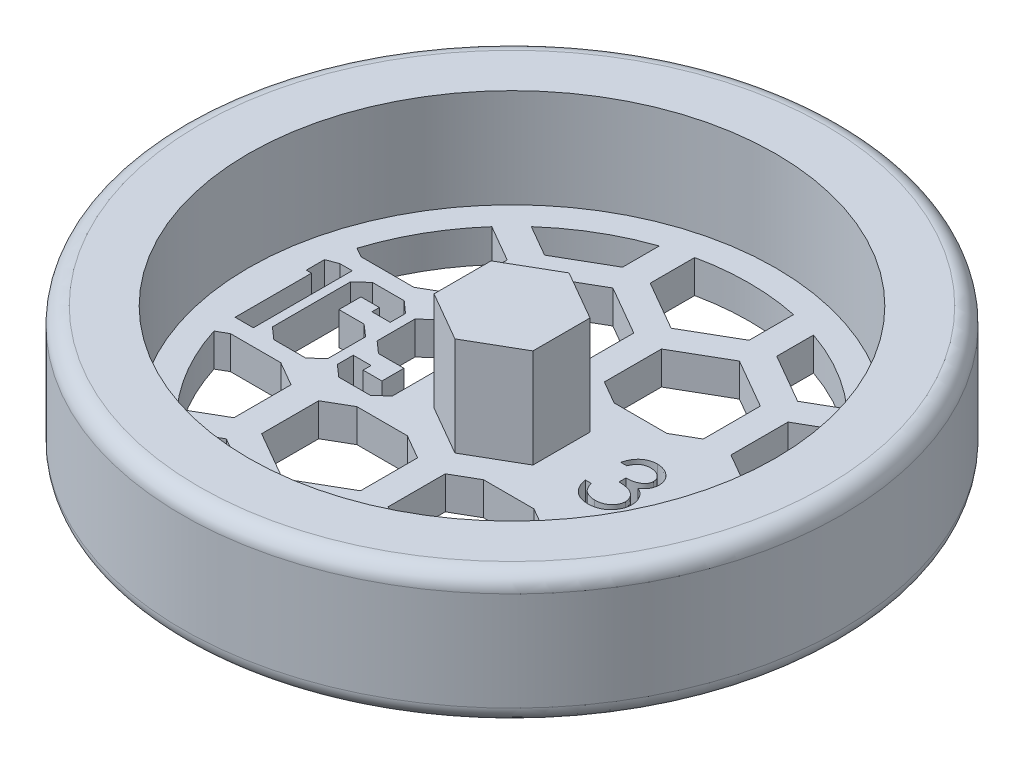
from build123d import *

# Parameters (mm, degrees)
BOSS_EXTRUDE1_DEPTH     = 9.525
CUT_EXTRUDE1_DEPTH      = 10.5250001
CUT_EXTRUDE1_DEPTH_BACK = 4.175
CUT_EXTRUDE3_DEPTH      = 10.5250001
CUT_EXTRUDE3_DEPTH_BACK = 4.1750001


with BuildPart() as part:
    # Sketch1 → Revolve1 (revolve)
    with BuildSketch(Plane.XY):
        with BuildLine():
            Line((0, 0), (30.1625, 0))
            ThreePointArc((30.1625, 0), (31.285032015, 0.464967985), (31.75, 1.5875))
            Line((31.75, 1.5875), (31.75, 11.1125))
            ThreePointArc((31.75, 11.1125), (31.285032015, 12.235032015), (30.1625, 12.7))
            Line((30.1625, 12.7), (25.4, 12.7))
            Line((25.4, 12.7), (25.4, 3.175))
            Line((25.4, 3.175), (0, 3.175))
            Line((0, 3.175), (0, 0))
        make_face()
    revolve(axis=Axis((0, 3.175, 0), (0, -1, 0)))

    # Sketch2 → Boss-Extrude1 (add)
    with BuildSketch(Plane(origin=(0, 3.175, 0), x_dir=(1, 0, 0), z_dir=(0, 1, 0))):
        Polygon((0, -5.499261314), (4.7625, -2.749630657), (4.7625, 2.749630657), (0, 5.499261314), (-4.7625, 2.749630657), (-4.7625, -2.749630657), align=None)
    extrude(amount=BOSS_EXTRUDE1_DEPTH)

    # Sketch3 → Cut-Extrude1 (cut, two sides)
    with BuildSketch(Plane(origin=(0, 3.175, 0), x_dir=(1, 0, 0), z_dir=(0, 1, 0))) as cut_extrude1_sk:
        Polygon((-20.156339589, -4.7625), (-21.915105149, -4.7625), (-21.915105149, 2.597727273), (-22.418122878, 2.597727273), (-22.418122878, 4.356492833), (-21.333041777, 4.7625), (-20.156339589, 4.7625), align=None)
        Polygon((-14.001558374, -3.767243493), (-15.129755281, -4.7625), (-18.185587986, -4.7625), (-19.313784892, -3.767243493), (-19.313784892, 3.761854017), (-18.198163429, 4.7625), (-15.1477202, 4.7625), (-14.019523293, 3.761854017), (-14.019523293, 2.288730668), (-15.783678329, 2.288730668), (-15.783678329, 3.00373444), (-17.555019332, 3.00373444), (-17.555019332, 0.882077518), (-15.129755281, 0.882077518), (-14.001558374, -0.105993022), align=None)
        Polygon((-7.769528008, -3.767243493), (-8.895928423, -4.7625), (-11.928406733, -4.7625), (-13.05660364, -3.767243493), (-13.05660364, -2.234835911), (-11.340953885, -2.234835911), (-11.340953885, -3.00373444), (-9.526497077, -3.00373444), (-9.526497077, -0.882077518), (-11.98230149, -0.882077518), (-13.105108921, 0.113178989), (-13.105108921, 3.761854017), (-11.98230149, 4.7625), (-8.908503866, 4.7625), (-7.769528008, 3.756464542), align=None)
        with BuildLine():
            Line((9.341826923, 1.709615385), (8.771955128, 1.709615385))
            add(Edge.make_bspline(
                [(8.771955128, 1.709615385), (8.787393884, 1.773537177), (8.81757539, 1.898499053), (8.880526702, 2.07703794), (8.949105351, 2.245990615), (9.031454155, 2.402193491), (9.12127718, 2.548785786), (9.224188404, 2.682442626), (9.3354399, 2.806563292), (9.458493737, 2.916714452), (9.587541451, 3.016459761), (9.724401404, 3.101504507), (9.866320083, 3.174664042), (10.014280767, 3.234935034), (10.168723964, 3.280338484), (10.328253424, 3.313280117), (10.493287202, 3.334672567), (10.605314974, 3.33676038), (10.662199519, 3.337820513)],
                knots=[0, 0, 0, 0, 0.000197149, 0.00038541, 0.000567311, 0.000743684, 0.000914521, 0.001082435, 0.001249032, 0.001413833, 0.00157717, 0.001737759, 0.001896483, 0.002055691, 0.002216275, 0.002378683, 0.002544033, 0.002714604, 0.002714604, 0.002714604, 0.002714604], degree=3))
            add(Edge.make_bspline(
                [(10.662199519, 3.337820513), (10.745081066, 3.335318195), (10.909036271, 3.330368142), (11.149906371, 3.285166236), (11.3821836, 3.213637782), (11.603325521, 3.114806877), (11.808736105, 2.992909894), (11.99150033, 2.847831015), (12.149140914, 2.682369425), (12.281392142, 2.499611772), (12.384942497, 2.30429392), (12.461299203, 2.103270777), (12.507784253, 1.897019201), (12.513808692, 1.757759566), (12.516826923, 1.687990785)],
                knots=[0, 0, 0, 0, 0.000248441, 0.000491463, 0.000732469, 0.000976186, 0.001216372, 0.001447214, 0.001673943, 0.001899893, 0.002121826, 0.002335172, 0.00254351, 0.002752682, 0.002752682, 0.002752682, 0.002752682], degree=3))
            add(Edge.make_bspline(
                [(12.516826923, 1.687990785), (12.514715836, 1.620849886), (12.510584768, 1.489465566), (12.475507902, 1.297656564), (12.416477825, 1.116878232), (12.334708398, 0.946369552), (12.228860157, 0.787211629), (12.100639693, 0.639046369), (11.949142007, 0.501216611), (11.834335933, 0.422259853), (11.775230369, 0.381610577)],
                knots=[0, 0, 0, 0, 0.000201307, 0.000393927, 0.000582588, 0.000770337, 0.000959438, 0.001154255, 0.001356876, 0.001571884, 0.001571884, 0.001571884, 0.001571884], degree=3))
            add(Edge.make_bspline(
                [(11.775230369, 0.381610577), (11.842779409, 0.348993037), (11.976613595, 0.284368257), (12.159040984, 0.157629954), (12.32464513, 0.011296295), (12.41699902, -0.102899661), (12.463401442, -0.160276442)],
                knots=[0, 0, 0, 0, 0.000224722, 0.00044524, 0.000664122, 0.000885153, 0.000885153, 0.000885153, 0.000885153], degree=3))
            add(Edge.make_bspline(
                [(12.463401442, -0.160276442), (12.493956449, -0.202109792), (12.554566103, -0.28509144), (12.629379143, -0.418507527), (12.697249965, -0.553402372), (12.750136791, -0.69339158), (12.791092236, -0.836852619), (12.820367608, -0.984031824), (12.838554264, -1.135049379), (12.841158765, -1.237216307), (12.842467949, -1.288571715)],
                knots=[0, 0, 0, 0, 0.000155272, 0.000308001, 0.000458187, 0.000607963, 0.000756132, 0.000905313, 0.00105773, 0.001211777, 0.001211777, 0.001211777, 0.001211777], degree=3))
            add(Edge.make_bspline(
                [(12.842467949, -1.288571715), (12.839212188, -1.377489352), (12.83271599, -1.554906178), (12.774651455, -1.817024601), (12.684638861, -2.073248013), (12.556809849, -2.318312364), (12.401021654, -2.547602484), (12.21567908, -2.752755216), (12.002888025, -2.929101255), (11.765569205, -3.076439812), (11.508453843, -3.194219471), (11.233452412, -3.275966546), (10.944527314, -3.329208573), (10.746394074, -3.334917893), (10.645663061, -3.337820513)],
                knots=[0, 0, 0, 0, 0.000266451, 0.000531648, 0.000801611, 0.001079241, 0.001358327, 0.001631199, 0.001905794, 0.002184633, 0.002466979, 0.002751475, 0.003043423, 0.003345349, 0.003345349, 0.003345349, 0.003345349], degree=3))
            add(Edge.make_bspline(
                [(10.645663061, -3.337820513), (10.577773759, -3.336245326), (10.444190251, -3.333145883), (10.247805618, -3.311957564), (10.060350535, -3.27325884), (9.881571551, -3.221182843), (9.711309842, -3.155157826), (9.550084965, -3.072936759), (9.396905015, -2.976214463), (9.25321549, -2.863849239), (9.119033517, -2.738153094), (8.997925003, -2.596894604), (8.887870807, -2.442685029), (8.791817734, -2.273733198), (8.705390692, -2.092222517), (8.634305242, -1.895828813), (8.571738567, -1.686307802), (8.542649282, -1.540298187), (8.527724359, -1.465384615)],
                knots=[0, 0, 0, 0, 0.000203669, 0.000400752, 0.000591596, 0.00077716, 0.000958812, 0.001138579, 0.001319262, 0.001501447, 0.001685017, 0.001869901, 0.002058732, 0.002252483, 0.002452209, 0.00266109, 0.002878455, 0.003107492, 0.003107492, 0.003107492, 0.003107492], degree=3))
            Line((8.527724359, -1.465384615), (9.097596154, -1.465384615))
            add(Edge.make_bspline(
                [(9.097596154, -1.465384615), (9.112442983, -1.514277825), (9.141321354, -1.609379365), (9.190478152, -1.746249634), (9.246482017, -1.871722102), (9.306561288, -1.986717195), (9.369659325, -2.092367411), (9.440262118, -2.185879087), (9.513140424, -2.271359526), (9.568075823, -2.319519036), (9.594961939, -2.343088942)],
                knots=[0, 0, 0, 0, 0.000153284, 0.000298151, 0.00043596, 0.000565114, 0.000687282, 0.000804565, 0.000916331, 0.001023461, 0.001023461, 0.001023461, 0.001023461], degree=3))
            add(Edge.make_bspline(
                [(9.594961939, -2.343088942), (9.630515728, -2.370499777), (9.701513559, -2.425236834), (9.81720735, -2.495089789), (9.938882215, -2.555616221), (10.069174552, -2.601850926), (10.205272779, -2.640998967), (10.349376713, -2.666617624), (10.500215007, -2.684194734), (10.603207949, -2.685745824), (10.655839343, -2.686538462)],
                knots=[0, 0, 0, 0, 0.000134583, 0.000268752, 0.000404717, 0.000541542, 0.000682898, 0.000829099, 0.000980107, 0.001137922, 0.001137922, 0.001137922, 0.001137922], degree=3))
            add(Edge.make_bspline(
                [(10.655839343, -2.686538462), (10.715263555, -2.685421033), (10.831462471, -2.683235999), (11.001016288, -2.663141503), (11.1623198, -2.633876324), (11.313582108, -2.588677055), (11.4567846, -2.532831796), (11.589919878, -2.462712546), (11.714735671, -2.380444265), (11.829633307, -2.286937506), (11.932948727, -2.184572794), (12.02391613, -2.077506222), (12.101249444, -1.966189217), (12.163631079, -1.850005769), (12.212889935, -1.729436997), (12.246423741, -1.604144549), (12.269740062, -1.475153795), (12.271638915, -1.387471237), (12.272596154, -1.343269231)],
                knots=[0, 0, 0, 0, 0.000178198, 0.000348452, 0.00051161, 0.000669393, 0.000821278, 0.000972056, 0.00111988, 0.001269077, 0.001415693, 0.001555599, 0.001690033, 0.001821502, 0.001950474, 0.002079778, 0.002210061, 0.002342506, 0.002342506, 0.002342506, 0.002342506], degree=3))
            add(Edge.make_bspline(
                [(12.272596154, -1.343269231), (12.26981975, -1.284102945), (12.264280756, -1.166064775), (12.221992334, -0.992405748), (12.15243468, -0.825086128), (12.055057409, -0.666960623), (11.93651973, -0.520410059), (11.797971971, -0.389651798), (11.638263614, -0.281756061), (11.491270423, -0.207209499), (11.361067924, -0.156342234), (11.24964287, -0.122460513), (11.124898746, -0.093770023), (10.988344085, -0.067077759), (10.838949964, -0.044360456), (10.676879026, -0.025416019), (10.50209843, -0.010257587), (10.381101601, -0.003488315), (10.31875, 0)],
                knots=[0, 0, 0, 0, 0.000177366, 0.000353849, 0.000532912, 0.000718999, 0.000908921, 0.001097014, 0.001288247, 0.00148508, 0.001590198, 0.001707288, 0.001834096, 0.001974049, 0.002124628, 0.0022873, 0.002463503, 0.002650842, 0.002650842, 0.002650842, 0.002650842], degree=3))
            Line((10.31875, 0), (10.31875, 0.651282051))
            add(Edge.make_bspline(
                [(10.31875, 0.651282051), (10.397310686, 0.652615195), (10.551191772, 0.655226497), (10.775971439, 0.686809601), (10.990915877, 0.730498741), (11.191261538, 0.797419018), (11.37386706, 0.875143557), (11.532289767, 0.965589708), (11.664310163, 1.066127896), (11.769286678, 1.178309916), (11.848261136, 1.298624359), (11.90600404, 1.424021724), (11.940113203, 1.555601092), (11.944666456, 1.645398561), (11.946955128, 1.690534856)],
                knots=[0, 0, 0, 0, 0.000235495, 0.000461277, 0.00067983, 0.000892625, 0.001093727, 0.001274383, 0.001438496, 0.001589702, 0.00173294, 0.001868428, 0.002002325, 0.002137646, 0.002137646, 0.002137646, 0.002137646], degree=3))
            add(Edge.make_bspline(
                [(11.946955128, 1.690534856), (11.946203268, 1.723695908), (11.944707479, 1.789668248), (11.925843846, 1.886052301), (11.897497372, 1.979489731), (11.858527006, 2.069583187), (11.806365931, 2.155707827), (11.743943641, 2.238597913), (11.669615802, 2.317780198), (11.584443348, 2.39158592), (11.492981931, 2.461924393), (11.392743053, 2.521639135), (11.28674908, 2.572702319), (11.174882664, 2.614810987), (11.056780773, 2.646487124), (10.932998304, 2.669230722), (10.803299221, 2.683450467), (10.714813365, 2.685497736), (10.669831731, 2.686538462)],
                knots=[0, 0, 0, 0, 9.9349e-05, 0.00019765, 0.000293417, 0.000391965, 0.000491224, 0.000594768, 0.000702764, 0.000816325, 0.000932589, 0.001048428, 0.001165628, 0.001285179, 0.00140645, 0.001531944, 0.001662444, 0.001797376, 0.001797376, 0.001797376, 0.001797376], degree=3))
            add(Edge.make_bspline(
                [(10.669831731, 2.686538462), (10.597529419, 2.684014133), (10.456306187, 2.679083533), (10.252716267, 2.635898066), (10.063451189, 2.566994972), (9.918782466, 2.484747922), (9.811952653, 2.403557849), (9.735613065, 2.332651234), (9.660645853, 2.253851682), (9.591982982, 2.162305773), (9.522543053, 2.064213168), (9.459325063, 1.954587346), (9.397893907, 1.836287945), (9.360877852, 1.752657293), (9.341826923, 1.709615385)],
                knots=[0, 0, 0, 0, 0.000216698, 0.000423262, 0.000621275, 0.000818969, 0.000919717, 0.001023253, 0.001131249, 0.001245492, 0.001366168, 0.00149161, 0.001624737, 0.00176591, 0.00176591, 0.00176591, 0.00176591], degree=3))
        make_face()
        Polygon((16.750160256, 3.337820513), (14.094150641, -4.070512821), (13.49375, -4.070512821), (16.149759615, 3.337820513), align=None)
        with BuildLine():
            add(Edge.make_bspline(
                [(20.325851362, 0.362530048), (20.377828012, 0.335428328), (20.479199838, 0.282570923), (20.62357563, 0.197461278), (20.755519561, 0.107761242), (20.878692437, 0.017707611), (20.990930231, -0.076148385), (21.090977951, -0.174179968), (21.181306919, -0.273940183), (21.260095512, -0.377118322), (21.329395488, -0.483440271), (21.389288933, -0.593185095), (21.440483001, -0.706112286), (21.481055761, -0.823454535), (21.514478155, -0.943488152), (21.537475324, -1.067763062), (21.54984316, -1.195460366), (21.552181436, -1.281762857), (21.553365385, -1.325460737)],
                knots=[0, 0, 0, 0, 0.00017584, 0.000342947, 0.000502414, 0.000654298, 0.000800555, 0.000940883, 0.001074198, 0.001203952, 0.001329909, 0.001454575, 0.001578694, 0.001701398, 0.001826685, 0.001952179, 0.002080017, 0.002211136, 0.002211136, 0.002211136, 0.002211136], degree=3))
            add(Edge.make_bspline(
                [(21.553365385, -1.325460737), (21.551965807, -1.386598052), (21.549195519, -1.507611738), (21.525065548, -1.686221112), (21.488937715, -1.859688202), (21.436179172, -2.027974978), (21.367756305, -2.190152841), (21.283434046, -2.346360616), (21.187982288, -2.499158505), (21.111324654, -2.593173705), (21.072536058, -2.640745192)],
                knots=[0, 0, 0, 0, 0.000183332, 0.000362883, 0.000539769, 0.000714376, 0.000891093, 0.001066933, 0.001246543, 0.001430513, 0.001430513, 0.001430513, 0.001430513], degree=3))
            add(Edge.make_bspline(
                [(21.072536058, -2.640745192), (21.02203274, -2.69625104), (20.921650188, -2.806576834), (20.749686877, -2.94981616), (20.560961459, -3.070192918), (20.356204198, -3.168294784), (20.135962429, -3.244650557), (19.900283077, -3.299519125), (19.648706686, -3.330946961), (19.475795331, -3.335489913), (19.387089343, -3.337820513)],
                knots=[0, 0, 0, 0, 0.000224931, 0.000447082, 0.000669033, 0.000894901, 0.001126621, 0.001366982, 0.001619583, 0.001885684, 0.001885684, 0.001885684, 0.001885684], degree=3))
            add(Edge.make_bspline(
                [(19.387089343, -3.337820513), (19.301793624, -3.335729589), (19.135816817, -3.331660862), (18.894230382, -3.304093822), (18.66903567, -3.255783264), (18.458923299, -3.18966233), (18.265159955, -3.10364663), (18.088297758, -2.996588517), (17.925784979, -2.872797186), (17.78255352, -2.728717359), (17.655393058, -2.574398076), (17.543691019, -2.415191584), (17.450846619, -2.25108335), (17.372238889, -2.084520369), (17.312062619, -1.913168061), (17.270384466, -1.737908037), (17.243915282, -1.559046421), (17.240393509, -1.438338993), (17.238621795, -1.377614183)],
                knots=[0, 0, 0, 0, 0.000255882, 0.000497919, 0.0007282, 0.000945837, 0.001157653, 0.001362498, 0.001564768, 0.001768948, 0.001970416, 0.002164142, 0.00235158, 0.002535397, 0.002716031, 0.002895284, 0.003075177, 0.003257296, 0.003257296, 0.003257296, 0.003257296], degree=3))
            add(Edge.make_bspline(
                [(17.238621795, -1.377614183), (17.239670236, -1.333056791), (17.241742326, -1.244995659), (17.256083979, -1.114894449), (17.279140759, -0.988264319), (17.310454345, -0.864637541), (17.35289235, -0.744914147), (17.404131649, -0.628526859), (17.46387962, -0.515344279), (17.532969734, -0.404747452), (17.613346263, -0.298286052), (17.704357456, -0.194153319), (17.807822304, -0.093965074), (17.92258977, 0.003502754), (18.047348292, 0.099979164), (18.185338383, 0.190250271), (18.332901983, 0.280706865), (18.437777505, 0.334787684), (18.491576522, 0.362530048)],
                knots=[0, 0, 0, 0, 0.000133661, 0.00026416, 0.000392157, 0.000519576, 0.000646302, 0.000772746, 0.000900774, 0.001029947, 0.00116351, 0.001300524, 0.00144445, 0.001595115, 0.001752092, 0.001917202, 0.002089542, 0.002271069, 0.002271069, 0.002271069, 0.002271069], degree=3))
            add(Edge.make_bspline(
                [(18.491576522, 0.362530048), (18.417932171, 0.402688843), (18.275336094, 0.480447509), (18.086524394, 0.623316714), (17.924344263, 0.778053179), (17.793253561, 0.947924378), (17.69007109, 1.127623707), (17.619280193, 1.31602685), (17.571389429, 1.509640371), (17.566645386, 1.641913042), (17.564262821, 1.708343349)],
                knots=[0, 0, 0, 0, 0.000251342, 0.000486669, 0.000707966, 0.000921948, 0.001128163, 0.001327073, 0.001524242, 0.001723173, 0.001723173, 0.001723173, 0.001723173], degree=3))
            add(Edge.make_bspline(
                [(17.564262821, 1.708343349), (17.567229947, 1.776011777), (17.573194389, 1.912037117), (17.621424128, 2.114522512), (17.700019106, 2.31339828), (17.806918629, 2.507700502), (17.940064007, 2.690853034), (18.099805597, 2.855120179), (18.282328721, 2.999013869), (18.48672228, 3.119802068), (18.70667945, 3.218106706), (18.938755121, 3.285921845), (19.178905758, 3.330255942), (19.342368764, 3.335275444), (19.425250401, 3.337820513)],
                knots=[0, 0, 0, 0, 0.000202829, 0.000407721, 0.00062079, 0.000842814, 0.001071289, 0.001297982, 0.001528034, 0.001766476, 0.002008514, 0.00224878, 0.002490326, 0.002738767, 0.002738767, 0.002738767, 0.002738767], degree=3))
            add(Edge.make_bspline(
                [(19.425250401, 3.337820513), (19.505993036, 3.335196433), (19.665208316, 3.330022047), (19.899241426, 3.286865854), (20.123169418, 3.214785154), (20.33622008, 3.117000192), (20.534579325, 2.996555313), (20.709843515, 2.850685156), (20.864661199, 2.687142628), (20.992721457, 2.504045634), (21.098245557, 2.310490025), (21.171725763, 2.10797488), (21.218810059, 1.900875873), (21.224748877, 1.760744066), (21.227724359, 1.690534856)],
                knots=[0, 0, 0, 0, 0.000242091, 0.000477377, 0.000711103, 0.000946181, 0.001179183, 0.001405083, 0.001628266, 0.001852736, 0.002073547, 0.002287642, 0.002497223, 0.002707663, 0.002707663, 0.002707663, 0.002707663], degree=3))
            add(Edge.make_bspline(
                [(21.227724359, 1.690534856), (21.225121656, 1.621634337), (21.220010096, 1.486317634), (21.177011634, 1.289056662), (21.104597479, 1.104322391), (21.005729498, 0.930018606), (20.876868971, 0.769306461), (20.719735983, 0.620142294), (20.535583301, 0.481300762), (20.397224265, 0.402948359), (20.325851362, 0.362530048)],
                knots=[0, 0, 0, 0, 0.000206544, 0.000405641, 0.000602178, 0.000799872, 0.001004492, 0.001217712, 0.00144846, 0.001694318, 0.001694318, 0.001694318, 0.001694318], degree=3))
        make_face()
    extrude(amount=CUT_EXTRUDE1_DEPTH, mode=Mode.SUBTRACT)
    extrude(cut_extrude1_sk.sketch, amount=-CUT_EXTRUDE1_DEPTH_BACK, mode=Mode.SUBTRACT)

    # Sketch4 → Cut-Extrude3 (cut, two sides)
    with BuildSketch(Plane(origin=(0, 3.175, 0), x_dir=(1, 0, 0), z_dir=(0, 1, 0))) as cut_extrude3_sk:
        with BuildLine():
            Line((-20.897368408, 6.35), (-15.805631592, 6.35))
            Line((-15.805631592, 6.35), (-13.589, 7.629772846))
            Line((-13.589, 7.629772846), (-13.589, 13.12903416))
            Line((-13.589, 13.12903416), (-17.108932059, 15.161267882))
            ThreePointArc((-17.108932059, 15.161267882), (-19.892207199, 11.264088635), (-21.802466353, 6.872558542))
            Line((-21.802466353, 6.872558542), (-20.897368408, 6.35))
        make_face()
        with BuildLine():
            ThreePointArc((-7.4295, 21.619022405), (-11.544244404, 19.730940706), (-15.206214659, 17.068996331))
            Line((-15.206214659, 17.068996331), (-12.192, 15.328738686))
            Line((-12.192, 15.328738686), (-7.4295, 18.078369343))
            Line((-7.4295, 18.078369343), (-7.4295, 21.619022405))
        make_face()
        Polygon((-8.705368408, 6.35), (-3.613631592, 6.35), (-1.397, 7.629772846), (-1.397, 13.12903416), (-6.1595, 15.878664817), (-10.922, 13.12903416), (-10.922, 7.629772846), align=None)
        with BuildLine():
            ThreePointArc((4.7625, 22.358403202), (0, 22.86), (-4.7625, 22.358403202))
            Line((-4.7625, 22.358403202), (-4.7625, 18.078369343))
            Line((-4.7625, 18.078369343), (0, 15.328738686))
            Line((0, 15.328738686), (4.7625, 18.078369343))
            Line((4.7625, 18.078369343), (4.7625, 22.358403202))
        make_face()
        Polygon((1.27, 7.629772846), (3.486631592, 6.35), (8.578368408, 6.35), (10.795, 7.629772846), (10.795, 13.12903416), (6.0325, 15.878664817), (1.27, 13.12903416), align=None)
        with BuildLine():
            Line((12.192, 15.328738686), (15.206214659, 17.068996331))
            ThreePointArc((15.206214659, 17.068996331), (11.544244404, 19.730940706), (7.4295, 21.619022405))
            Line((7.4295, 21.619022405), (7.4295, 18.078369343))
            Line((7.4295, 18.078369343), (12.192, 15.328738686))
        make_face()
        with BuildLine():
            Line((13.462, 7.629772846), (15.678631592, 6.35))
            Line((15.678631592, 6.35), (20.770368408, 6.35))
            Line((20.770368408, 6.35), (21.782830062, 6.934545009))
            ThreePointArc((21.782830062, 6.934545009), (19.860135036, 11.320540463), (17.065866333, 15.209727358))
            Line((17.065866333, 15.209727358), (13.462, 13.12903416))
            Line((13.462, 13.12903416), (13.462, 7.629772846))
        make_face()
        with BuildLine():
            Line((20.650522628, -6.35), (15.798477372, -6.35))
            Line((15.798477372, -6.35), (13.462, -7.69896584))
            Line((13.462, -7.69896584), (13.462, -13.198227154))
            Line((13.462, -13.198227154), (17.025077395, -15.255370847))
            ThreePointArc((17.025077395, -15.255370847), (19.829723184, -11.373727554), (21.764149656, -6.992952864))
            Line((21.764149656, -6.992952864), (20.650522628, -6.35))
        make_face()
        with BuildLine():
            ThreePointArc((7.4295, -21.619022405), (11.544244404, -19.730940706), (15.206214659, -17.068996331))
            Line((15.206214659, -17.068996331), (12.192, -15.328738686))
            Line((12.192, -15.328738686), (7.4295, -18.078369343))
            Line((7.4295, -18.078369343), (7.4295, -21.619022405))
        make_face()
        Polygon((8.458522628, -6.35), (3.606477372, -6.35), (1.27, -7.69896584), (1.27, -13.198227154), (6.0325, -15.947857811), (10.795, -13.198227154), (10.795, -7.69896584), align=None)
        with BuildLine():
            Line((-4.7625, -18.078369343), (-4.7625, -22.358403202))
            ThreePointArc((-4.7625, -22.358403202), (0, -22.86), (4.7625, -22.358403202))
            Line((4.7625, -22.358403202), (4.7625, -18.078369343))
            Line((4.7625, -18.078369343), (0, -15.328738686))
            Line((0, -15.328738686), (-4.7625, -18.078369343))
        make_face()
        Polygon((-1.397, -7.69896584), (-3.733477372, -6.35), (-8.585522628, -6.35), (-10.922, -7.69896584), (-10.922, -13.198227154), (-6.1595, -15.947857811), (-1.397, -13.198227154), align=None)
        with BuildLine():
            Line((-12.192, -15.328738686), (-15.206214659, -17.068996331))
            ThreePointArc((-15.206214659, -17.068996331), (-11.544244404, -19.730940706), (-7.4295, -21.619022405))
            Line((-7.4295, -21.619022405), (-7.4295, -18.078369343))
            Line((-7.4295, -18.078369343), (-12.192, -15.328738686))
        make_face()
        with BuildLine():
            Line((-13.589, -7.69896584), (-15.925477372, -6.35))
            Line((-15.925477372, -6.35), (-20.777522628, -6.35))
            Line((-20.777522628, -6.35), (-21.783940581, -6.931055676))
            ThreePointArc((-21.783940581, -6.931055676), (-19.861945981, -11.317362848), (-17.068296652, -15.207000013))
            Line((-17.068296652, -15.207000013), (-13.589, -13.198227154))
            Line((-13.589, -13.198227154), (-13.589, -7.69896584))
        make_face()
    extrude(amount=CUT_EXTRUDE3_DEPTH, mode=Mode.SUBTRACT)
    extrude(cut_extrude3_sk.sketch, amount=-CUT_EXTRUDE3_DEPTH_BACK, mode=Mode.SUBTRACT)


solid = part.part
